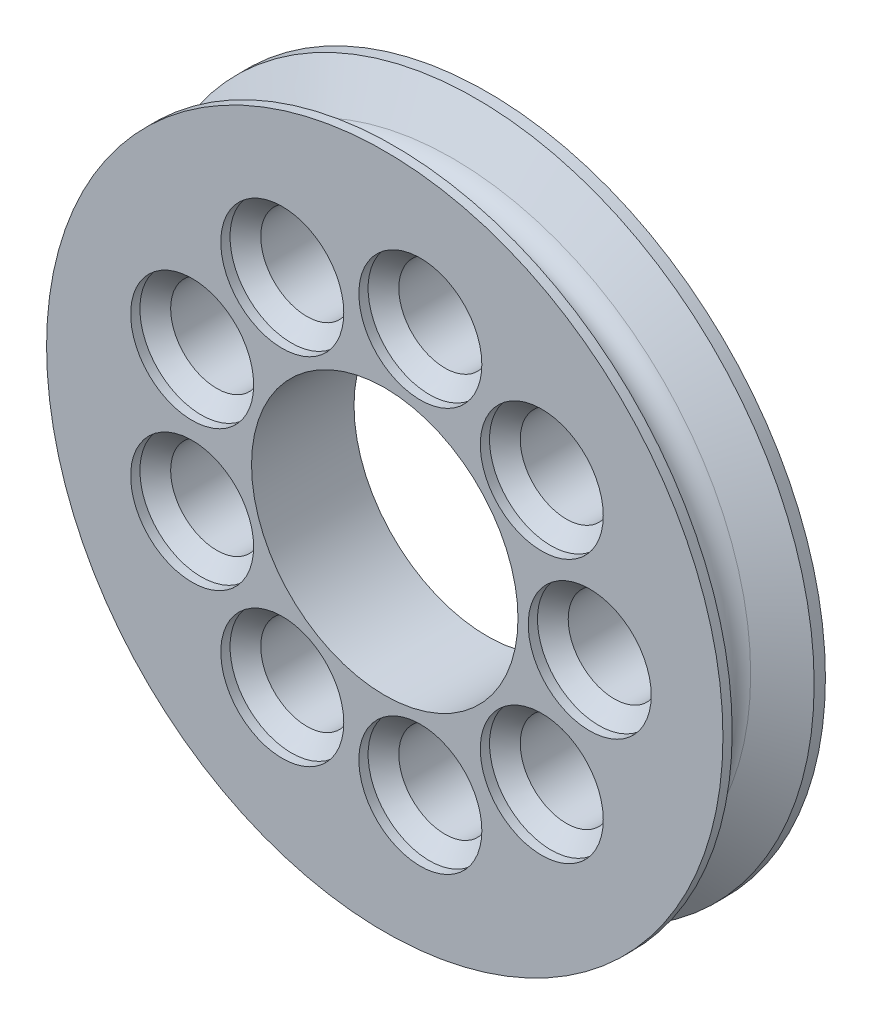
from build123d import *

# Parameters (mm, degrees)
SKETCH5_R                    = 16.51
CUT_EXTRUDE2_DEPTH           = 19.304
CUT_EXTRUDE2_DEPTH_BACK      = 110.744
SKETCH2_R                    = 7.62
CUT_EXTRUDE3_DEPTH           = 1.905
CUT_EXTRUDE3_TAPER           = 45
CUT_EXTRUDE3_OTHER_WAY_DEPTH = 9.398
SKETCH9_R                    = 7.62
CUT_EXTRUDE5_DEPTH           = 1.905
CUT_EXTRUDE5_TAPER           = 45
CUT_EXTRUDE5_OTHER_WAY_DEPTH = 127
SKETCH10_R                   = 5.715
CUT_EXTRUDE6_DEPTH           = 1.905
CUT_EXTRUDE6_DEPTH_BACK      = 48.641


with BuildPart() as part:
    # Sketch1 → Revolve1 (revolve)
    with BuildSketch(Plane(origin=(0, 0, 0), x_dir=(1, 0, 0), z_dir=(0, 1, 0))):
        with BuildLine():
            Line((0, 0), (4.988818102, 2.880295474))
            ThreePointArc((4.988818102, 2.880295474), (6.258818102, 5.08), (4.988818102, 7.279704526))
            Line((4.988818102, 7.279704526), (0, 10.16))
            Line((0, 10.16), (0, 11.555300166))
            Line((0, 11.555300166), (41.91, 11.555300166))
            Line((41.91, 11.555300166), (41.91, -1.144699834))
            Line((41.91, -1.144699834), (0, -1.144699834))
            Line((0, -1.144699834), (0, 0))
        make_face()
    revolve(axis=Axis((41.91, 0, -11.555300166), (0, 0, 1)))

    # Sketch5 → Cut-Extrude2 (cut, two sides)
    with BuildSketch(Plane.XY.offset(1.144699834)) as cut_extrude2_sk:
        with Locations((41.91, 0)):
            Circle(SKETCH5_R)
    extrude(amount=CUT_EXTRUDE2_DEPTH, mode=Mode.SUBTRACT)
    extrude(cut_extrude2_sk.sketch, amount=-CUT_EXTRUDE2_DEPTH_BACK, mode=Mode.SUBTRACT)

    # Sketch2 → Cut-Extrude3 (cut)
    with BuildSketch(Plane.XY):
        with Locations((67.31, 0)):
            Circle(SKETCH2_R)
        with Locations((61.367528855, -16.326805286)):
            Circle(SKETCH2_R)
        with Locations((61.367528855, 16.326805286)):
            Circle(SKETCH2_R)
        with Locations((46.320663713, 25.014116927)):
            Circle(SKETCH2_R)
        with Locations((29.21, 21.997045256)):
            Circle(SKETCH2_R)
        with Locations((18.041807432, 8.68731164)):
            Circle(SKETCH2_R)
        with Locations((18.041807432, -8.68731164)):
            Circle(SKETCH2_R)
        with Locations((29.21, -21.997045256)):
            Circle(SKETCH2_R)
        with Locations((46.320663713, -25.014116927)):
            Circle(SKETCH2_R)
    extrude(amount=-CUT_EXTRUDE3_DEPTH, taper=CUT_EXTRUDE3_TAPER, mode=Mode.SUBTRACT)

    # Sketch2 → Cut-Extrude3 other way (cut)
    with BuildSketch(Plane.XY):
        with Locations((67.31, 0)):
            Circle(SKETCH2_R)
        with Locations((61.367528855, -16.326805286)):
            Circle(SKETCH2_R)
        with Locations((61.367528855, 16.326805286)):
            Circle(SKETCH2_R)
        with Locations((46.320663713, 25.014116927)):
            Circle(SKETCH2_R)
        with Locations((29.21, 21.997045256)):
            Circle(SKETCH2_R)
        with Locations((18.041807432, 8.68731164)):
            Circle(SKETCH2_R)
        with Locations((18.041807432, -8.68731164)):
            Circle(SKETCH2_R)
        with Locations((29.21, -21.997045256)):
            Circle(SKETCH2_R)
        with Locations((46.320663713, -25.014116927)):
            Circle(SKETCH2_R)
    extrude(amount=CUT_EXTRUDE3_OTHER_WAY_DEPTH, mode=Mode.SUBTRACT)

    # Sketch9 → Cut-Extrude5 (cut)
    with BuildSketch(Plane(origin=(0, 0, -11.555300166), x_dir=(-1, 0, 0), z_dir=(0, 0, -1))):
        with Locations((-67.31, 0)):
            Circle(SKETCH9_R)
        with Locations((-61.367528855, 16.326805286)):
            Circle(SKETCH9_R)
        with Locations((-46.320663713, 25.014116927)):
            Circle(SKETCH9_R)
        with Locations((-29.21, 21.997045256)):
            Circle(SKETCH9_R)
        with Locations((-18.041807432, 8.68731164)):
            Circle(SKETCH9_R)
        with Locations((-18.041807432, -8.68731164)):
            Circle(SKETCH9_R)
        with Locations((-29.21, -21.997045256)):
            Circle(SKETCH9_R)
        with Locations((-46.320663713, -25.014116927)):
            Circle(SKETCH9_R)
        with Locations((-61.367528855, -16.326805286)):
            Circle(SKETCH9_R)
    extrude(amount=-CUT_EXTRUDE5_DEPTH, taper=CUT_EXTRUDE5_TAPER, mode=Mode.SUBTRACT)

    # Sketch9 → Cut-Extrude5 other way (cut)
    with BuildSketch(Plane(origin=(0, 0, -11.555300166), x_dir=(-1, 0, 0), z_dir=(0, 0, -1))):
        with Locations((-67.31, 0)):
            Circle(SKETCH9_R)
        with Locations((-61.367528855, 16.326805286)):
            Circle(SKETCH9_R)
        with Locations((-46.320663713, 25.014116927)):
            Circle(SKETCH9_R)
        with Locations((-29.21, 21.997045256)):
            Circle(SKETCH9_R)
        with Locations((-18.041807432, 8.68731164)):
            Circle(SKETCH9_R)
        with Locations((-18.041807432, -8.68731164)):
            Circle(SKETCH9_R)
        with Locations((-29.21, -21.997045256)):
            Circle(SKETCH9_R)
        with Locations((-46.320663713, -25.014116927)):
            Circle(SKETCH9_R)
        with Locations((-61.367528855, -16.326805286)):
            Circle(SKETCH9_R)
    extrude(amount=CUT_EXTRUDE5_OTHER_WAY_DEPTH, mode=Mode.SUBTRACT)

    # Sketch10 → Cut-Extrude6 (cut, two sides)
    with BuildSketch(Plane.XY.offset(1.144699834)) as cut_extrude6_sk:
        with Locations((29.21, 21.997045256)):
            Circle(SKETCH10_R)
        with Locations((46.320663713, 25.014116927)):
            Circle(SKETCH10_R)
        with Locations((61.367528855, 16.326805286)):
            Circle(SKETCH10_R)
        with Locations((67.31, 0)):
            Circle(SKETCH10_R)
        with Locations((61.367528855, -16.326805286)):
            Circle(SKETCH10_R)
        with Locations((46.320663713, -25.014116927)):
            Circle(SKETCH10_R)
        with Locations((29.21, -21.997045256)):
            Circle(SKETCH10_R)
        with Locations((18.041807432, -8.68731164)):
            Circle(SKETCH10_R)
        with Locations((18.041807432, 8.68731164)):
            Circle(SKETCH10_R)
    extrude(amount=CUT_EXTRUDE6_DEPTH, mode=Mode.SUBTRACT)
    extrude(cut_extrude6_sk.sketch, amount=-CUT_EXTRUDE6_DEPTH_BACK, mode=Mode.SUBTRACT)


solid = part.part
